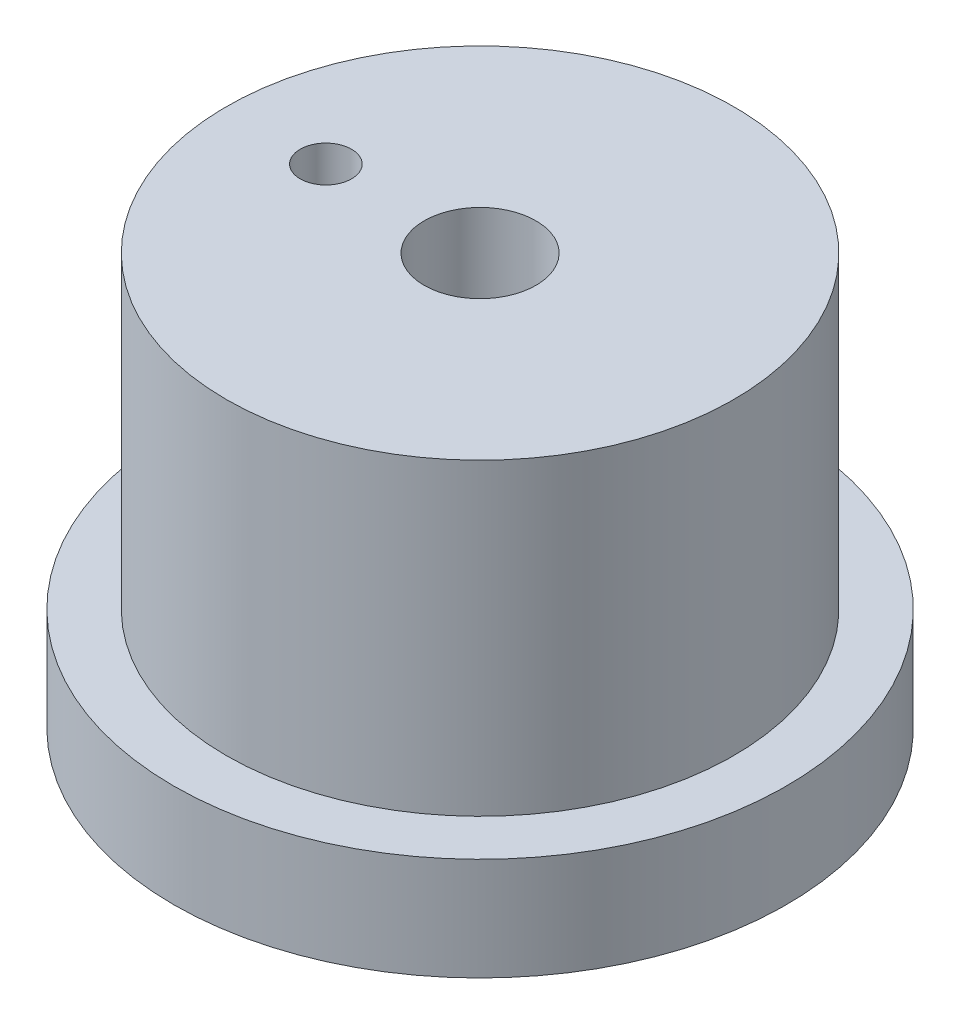
from build123d import *

# Parameters (mm, degrees)
SKETCH1_R                      = 9.4615
EXTRUDE1_DEPTH                 = 3.175
SKETCH2_R                      = 7.8359
EXTRUDE2_DEPTH                 = 9.525
SKETCH3_R                      = 7.4295
CUT_EXTRUDE1_DEPTH             = 0.635
F_8_32_TAPPED_HOLE1_D          = 3.4544
F_8_32_TAPPED_HOLE1_DEPTH      = 12.065
F_1_16_0_0625_DIAMETER_HOLE1_D = 1.5875


with BuildPart() as part:
    # Sketch1 → Extrude1 (new body)
    with BuildSketch(Plane(origin=(0, 0, 0), x_dir=(1, 0, 0), z_dir=(0, 1, 0))):
        with Locations(Location((0, 0, 0), (0, 0, 270))):  # turned: the seam where the file's is
            Circle(SKETCH1_R)
    extrude(amount=EXTRUDE1_DEPTH)

    # Sketch2 → Extrude2 (add)
    with BuildSketch(Plane(origin=(0, 3.175, 0), x_dir=(1, 0, 0), z_dir=(0, 1, 0))):
        with Locations(Location((0, 0, 0), (0, 0, 270))):  # turned: the seam where the file's is
            Circle(SKETCH2_R)
    extrude(amount=EXTRUDE2_DEPTH)

    # Sketch3 → Cut-Extrude1 (cut)
    with BuildSketch(Plane.XZ):
        with Locations(Location((0, 0, 0), (0, 0, 270))):  # turned: the seam where the file's is
            Circle(SKETCH3_R)
    extrude(amount=-CUT_EXTRUDE1_DEPTH, mode=Mode.SUBTRACT)

    # #8-32 Tapped Hole1
    with Locations(Plane.ZX.offset(12.7)):
        with Locations((0, 0)):
            Hole(F_8_32_TAPPED_HOLE1_D / 2, depth=F_8_32_TAPPED_HOLE1_DEPTH)

    # 1/16 (0.0625) Diameter Hole1 (through all)
    with Locations(Plane(origin=(0, 12.7, 0), x_dir=(1, 0, 0), z_dir=(0, 1, 0))):
        with Locations((-4.7625, 0)):
            Hole(F_1_16_0_0625_DIAMETER_HOLE1_D / 2)


solid = part.part
